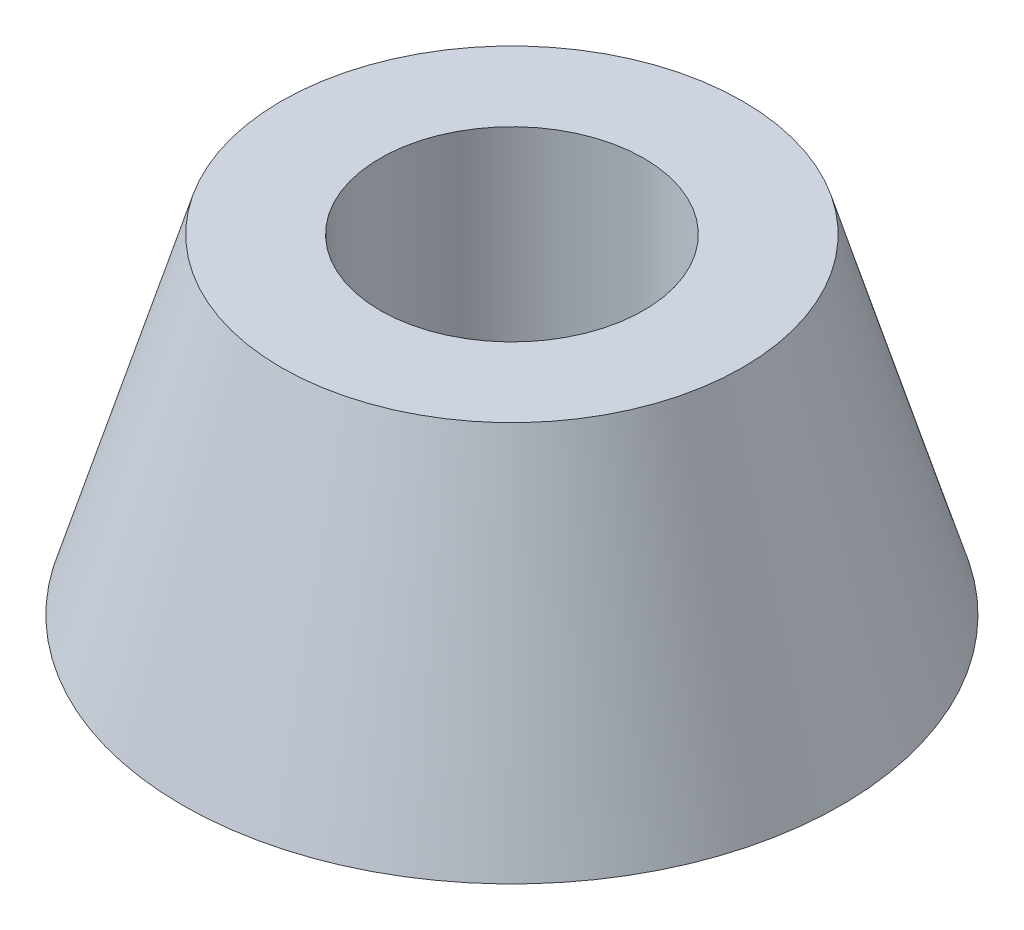
from build123d import *

# Parameters (mm, degrees)
SKETCH1_R           = 10
BOSS_EXTRUDE1_DEPTH = 10
BOSS_EXTRUDE1_TAPER = 16.69924423
SKETCH2_R           = 4
CUT_EXTRUDE1_DEPTH  = 7
SKETCH3_R           = 2.5
CUT_EXTRUDE2_DEPTH  = 4.0000001


with BuildPart() as part:
    # Sketch1 → Boss-Extrude1 (new body)
    with BuildSketch(Plane(origin=(0, 0, 0), x_dir=(1, 0, 0), z_dir=(0, 1, 0))):
        Circle(SKETCH1_R)
    extrude(amount=BOSS_EXTRUDE1_DEPTH, taper=BOSS_EXTRUDE1_TAPER)

    # Sketch2 → Cut-Extrude1 (cut)
    with BuildSketch(Plane(origin=(0, 10, 0), x_dir=(1, 0, 0), z_dir=(0, 1, 0))):
        Circle(SKETCH2_R)
    extrude(amount=-CUT_EXTRUDE1_DEPTH, mode=Mode.SUBTRACT)

    # Sketch3 → Cut-Extrude2 (cut, through all)
    with BuildSketch(Plane(origin=(0, 3, 0), x_dir=(1, 0, 0), z_dir=(0, 1, 0))):
        Circle(SKETCH3_R)
    extrude(amount=-CUT_EXTRUDE2_DEPTH, mode=Mode.SUBTRACT)


solid = part.part
